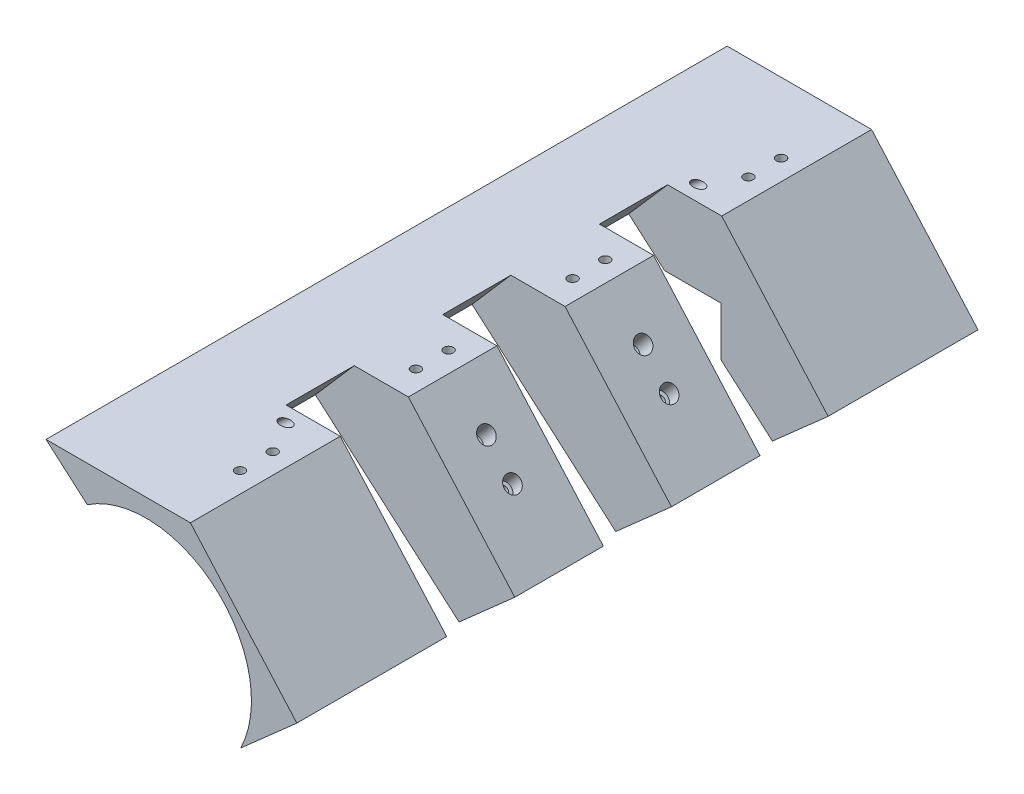
from build123d import *

# Parameters (mm, degrees)
EXTRUDE_1_DEPTH      = 250
SKETCH_2_R           = 38.7
CUT_EXTRUDE_1_DEPTH  = 42
SKETCH_3_W           = 28.23457759
SKETCH_3_H           = 26.953334418
CUT_EXTRUDE_2_DEPTH  = 14
SKETCH_4_W           = 170
SKETCH_4_H           = 25
CUT_EXTRUDE_3_DEPTH  = 78
SKETCH_7_R           = 1.75
CUT_EXTRUDE_5_DEPTH  = 25
SKETCH_6_R           = 1.75
CUT_EXTRUDE_6_DEPTH  = 90
SKETCH_5_R           = 1.75
CUT_EXTRUDE_8_DEPTH  = 10
SKETCH_9_R           = 1.75
CUT_EXTRUDE_9_DEPTH  = 124
SKETCH_10_W          = 17.333433977
SKETCH_10_H          = 22.880132851
CUT_EXTRUDE_10_DEPTH = 31
SKETCH_11_R          = 3
CUT_EXTRUDE_11_DEPTH = 10


with BuildPart() as part:
    # 草图1 → 凸台-拉伸1 (new body)
    with BuildSketch(Plane.XY):
        Polygon((0, 0), (53, 0), (92.057126275, -44.146050576), (71.602312757, -62.242940876), (15.094191604, -13.12118058), align=None)
    extrude(amount=EXTRUDE_1_DEPTH)

    # 草图2 → 切除-拉伸1 (cut)
    with BuildSketch(Plane.XY.offset(250)):
        with Locations((36.7, -45.33)):
            Circle(SKETCH_2_R)
    cut_extrude_1 = extrude(amount=-CUT_EXTRUDE_1_DEPTH, mode=Mode.SUBTRACT)

    # 草图3 → 切除-拉伸2 (cut)
    with BuildSketch(Plane.XY.offset(208)):
        with Locations((38.582711205, -41.306667209)):
            Rectangle(SKETCH_3_W, SKETCH_3_H)
    cut_extrude_2 = extrude(amount=-CUT_EXTRUDE_2_DEPTH, mode=Mode.SUBTRACT)

    # 草图4 → 切除-拉伸3 (cut)
    with BuildSketch(Plane(origin=(0, 0, 0), x_dir=(0.75470958, -0.656059029, 0), z_dir=(-0.656059029, -0.75470958, 0))):
        with Locations((110, 67.5)):
            Rectangle(SKETCH_4_W, SKETCH_4_H)
        with Locations((110, 125)):
            Rectangle(SKETCH_4_W, SKETCH_4_H)
        with Locations((110, 182.5)):
            Rectangle(SKETCH_4_W, SKETCH_4_H)
    extrude(amount=-CUT_EXTRUDE_3_DEPTH, mode=Mode.SUBTRACT)

    # 镜向1: 切除-拉伸1, 切除-拉伸2 across plane
    add(cut_extrude_1.mirror(Plane.XY.offset(125)), mode=Mode.SUBTRACT)
    add(cut_extrude_2.mirror(Plane.XY.offset(125)), mode=Mode.SUBTRACT)

    # 草图7 → 切除-拉伸5 (cut)
    with BuildSketch(Plane(origin=(0, 0, 0), x_dir=(1, 0, 0), z_dir=(0, 1, 0))):
        with Locations((45.5, -159.75)):
            Circle(SKETCH_7_R)
        with Locations((45.5, -147.75)):
            Circle(SKETCH_7_R)
        with Locations((45.5, -102.25)):
            Circle(SKETCH_7_R)
        with Locations((45.5, -90.25)):
            Circle(SKETCH_7_R)
    extrude(amount=-CUT_EXTRUDE_5_DEPTH, mode=Mode.SUBTRACT)

    # 草图6 → 切除-拉伸6 (cut)
    with BuildSketch(Plane(origin=(0, 0, 0), x_dir=(0.75470958, -0.656059029, 0), z_dir=(-0.656059029, -0.75470958, 0))):
        with Locations((72.838810202, 96.25)):
            Circle(SKETCH_6_R)
        with Locations((58.538810202, 96.25)):
            Circle(SKETCH_6_R)
        with Locations((72.838810202, 153.75)):
            Circle(SKETCH_6_R)
        with Locations((58.538810202, 153.75)):
            Circle(SKETCH_6_R)
    extrude(amount=-CUT_EXTRUDE_6_DEPTH, mode=Mode.SUBTRACT)

    # 草图5 → 切除-拉伸8 (cut)
    with BuildSketch(Plane(origin=(0, 0, 0), x_dir=(1, 0, 0), z_dir=(0, 1, 0))):
        with Locations((45.5, -212.3)):
            Circle(SKETCH_5_R)
        with Locations((45.5, -224.3)):
            Circle(SKETCH_5_R)
        with Locations((45.5, -25.7)):
            Circle(SKETCH_5_R)
        with Locations((45.5, -37.7)):
            Circle(SKETCH_5_R)
    extrude(amount=-CUT_EXTRUDE_8_DEPTH, mode=Mode.SUBTRACT)

    # 草图9 → 切除-拉伸9 (cut)
    with BuildSketch(Plane(origin=(29.7295376, 26.302473018, 0), x_dir=(0, 0, -1), z_dir=(0.748955721, 0.662620048, 0))):
        with Locations((-49.264197296, -25.601913803)):
            Circle(SKETCH_9_R)
        with Locations((-200.735802704, -25.601913803)):
            Circle(SKETCH_9_R)
    extrude(amount=-CUT_EXTRUDE_9_DEPTH, mode=Mode.SUBTRACT)

    # 草图10 → 切除-拉伸10 (cut)
    with BuildSketch(Plane(origin=(0, -25, 0), x_dir=(1, 0, 0), z_dir=(0, 1, 0))):
        with Locations((46.622123833, -96.2830381)):
            Rectangle(SKETCH_10_W, SKETCH_10_H)
    cut_extrude_10 = extrude(amount=-CUT_EXTRUDE_10_DEPTH, mode=Mode.SUBTRACT)

    # 镜向2: 切除-拉伸10 across plane
    add(cut_extrude_10.mirror(Plane.XY.offset(125)), mode=Mode.SUBTRACT)

    # 草图11 → 切除-拉伸11 (cut)
    with BuildSketch(Plane(origin=(22.962066015, 26.414835308, 0), x_dir=(-0.75470958, 0.656059029, 0), z_dir=(-0.656059029, -0.75470958, 0))):
        with Locations((-58.538810202, -96.25)):
            Circle(SKETCH_11_R)
        with Locations((-72.838810202, -96.25)):
            Circle(SKETCH_11_R)
        with Locations((-58.538810202, -153.75)):
            Circle(SKETCH_11_R)
        with Locations((-72.838810202, -153.75)):
            Circle(SKETCH_11_R)
    extrude(amount=CUT_EXTRUDE_11_DEPTH, mode=Mode.SUBTRACT)


solid = part.part
